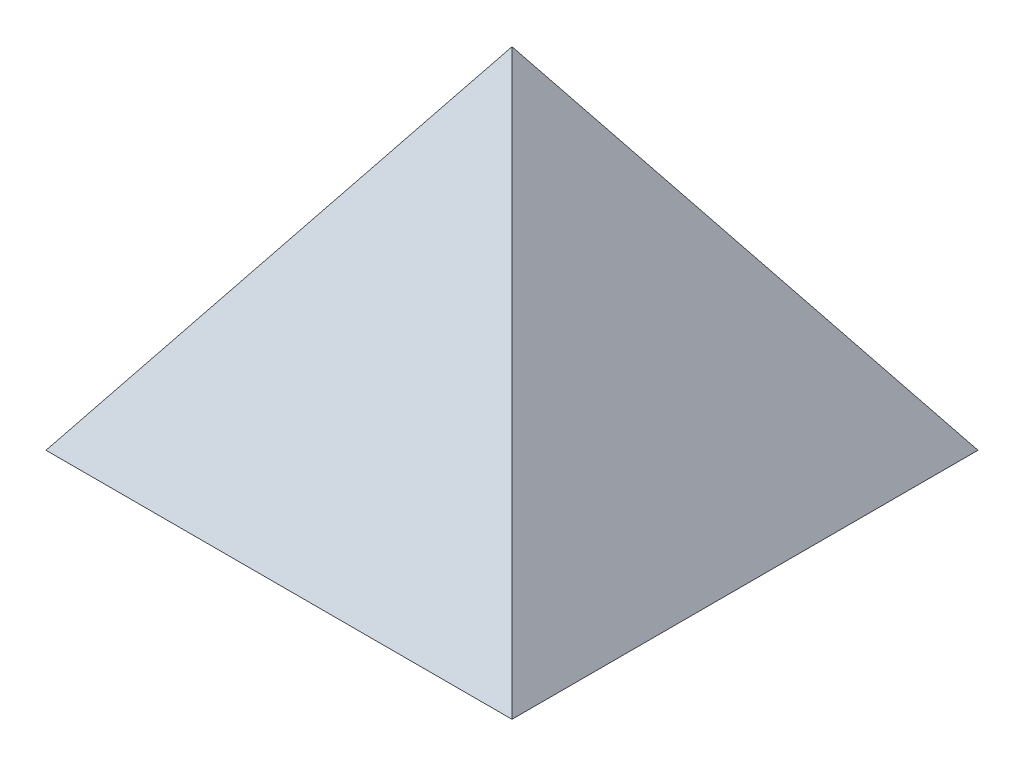
from build123d import *

# Parameters (mm, degrees)
SHELL2_T            = -2.54
SKETCH8_W           = 95.49459984
SKETCH8_H           = 95.49459984
BOSS_EXTRUDE1_DEPTH = 2.54
SKETCH9_R           = 5.715
CUT_EXTRUDE1_DEPTH  = 2.54


with BuildPart() as part:
    # Sketch3 → Loft1 section 0
    with BuildSketch(Plane(origin=(0, 0, 0), x_dir=(1, 0, 0), z_dir=(0, 1, 0)), mode=Mode.PRIVATE) as loft1_s0:
        with BuildLine():
            Line((-50.8, -50.8), (50.8, -50.8))
            Line((50.8, -50.8), (50.8, 50.8))
            Line((50.8, 50.8), (-50.8, 50.8))
            Line((-50.8, 50.8), (-50.8, -50.8))
        make_face()
    loft([Vertex(0, 76.2, 0), loft1_s0.sketch])

    # Shell2
    shell2_openings = [part.faces().sort_by_distance(p)[0] for p in [
        (0, 0, 0),
    ]]
    offset(amount=SHELL2_T, openings=shell2_openings, kind=Kind.INTERSECTION)

    # Sketch8 → Boss-Extrude1 (add)
    with BuildSketch(Plane.XZ):
        Rectangle(SKETCH8_W, SKETCH8_H)
    extrude(amount=-BOSS_EXTRUDE1_DEPTH)

    # Sketch9 → Cut-Extrude1 (cut)
    with BuildSketch(Plane(origin=(0, 23.446153846, -35.169230769), x_dir=(-1, 0, 0), z_dir=(0, 0.5547001962252291, -0.8320502943378436))):
        with Locations((35.4584, -19.288769968)):
            Circle(SKETCH9_R)
    extrude(amount=-CUT_EXTRUDE1_DEPTH, mode=Mode.SUBTRACT)


solid = part.part
